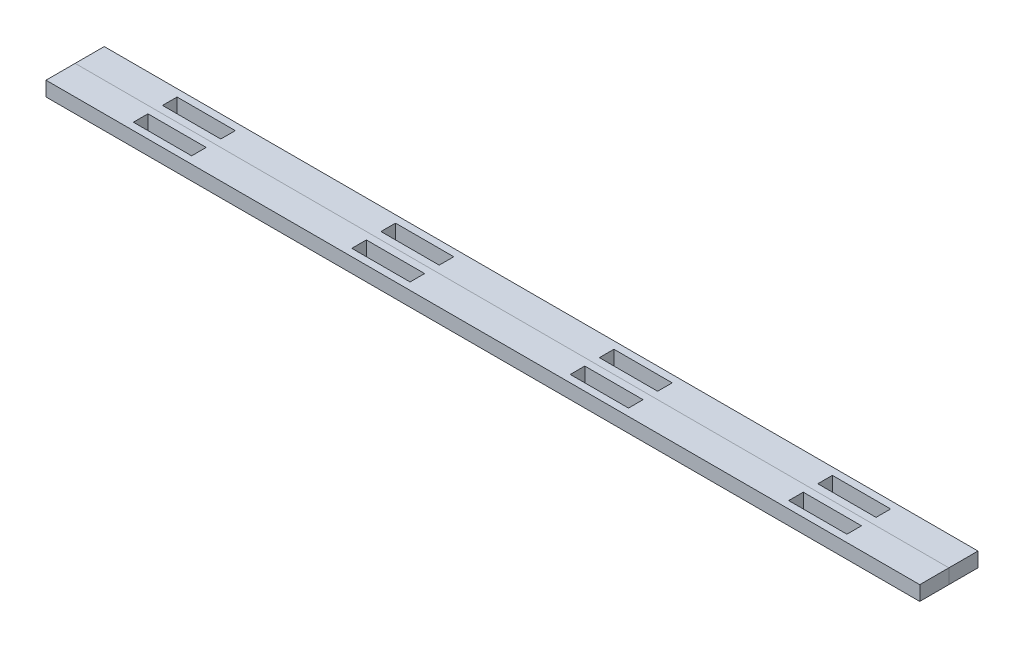
from build123d import *

# Parameters (mm, degrees)
SKETCH1_W           = 381
SKETCH1_H           = 12.7
BOSS_EXTRUDE1_DEPTH = 6.35
SKETCH2_W           = 25.4
SKETCH2_H           = 6.35
CUT_EXTRUDE1_DEPTH  = 7.35
LPATTERN1_COUNT     = 4
LPATTERN1_PITCH     = 95.25
LPATTERN2_COUNT     = 2
LPATTERN2_PITCH     = 12.7


with BuildPart() as part:
    # Sketch1 → Boss-Extrude1 (new body)
    with BuildSketch(Plane(origin=(0, 0, 0), x_dir=(1, 0, 0), z_dir=(0, 1, 0))):
        Rectangle(SKETCH1_W, SKETCH1_H)
    extrude(amount=BOSS_EXTRUDE1_DEPTH)

    # Sketch2 → Cut-Extrude1 (cut, through all)
    with BuildSketch(Plane(origin=(0, 6.35, 0), x_dir=(1, 0, 0), z_dir=(0, 1, 0))):
        with Locations((-142.875, 0)):
            Rectangle(SKETCH2_W, SKETCH2_H)
    cut_extrude1 = extrude(amount=-CUT_EXTRUDE1_DEPTH, mode=Mode.SUBTRACT)

    # LPattern1: Cut-Extrude1 ×4
    with Locations(*[(i * LPATTERN1_PITCH, 0, 0) for i in range(1, LPATTERN1_COUNT)]):
        add(cut_extrude1, mode=Mode.SUBTRACT)


with BuildPart() as lpattern2_1:
    # LPattern2: pattern copy
    add(part.part.moved(Location(Vector(0, 0, 1) * (1 * LPATTERN2_PITCH))))


solid = Compound([part.part, lpattern2_1.part])
